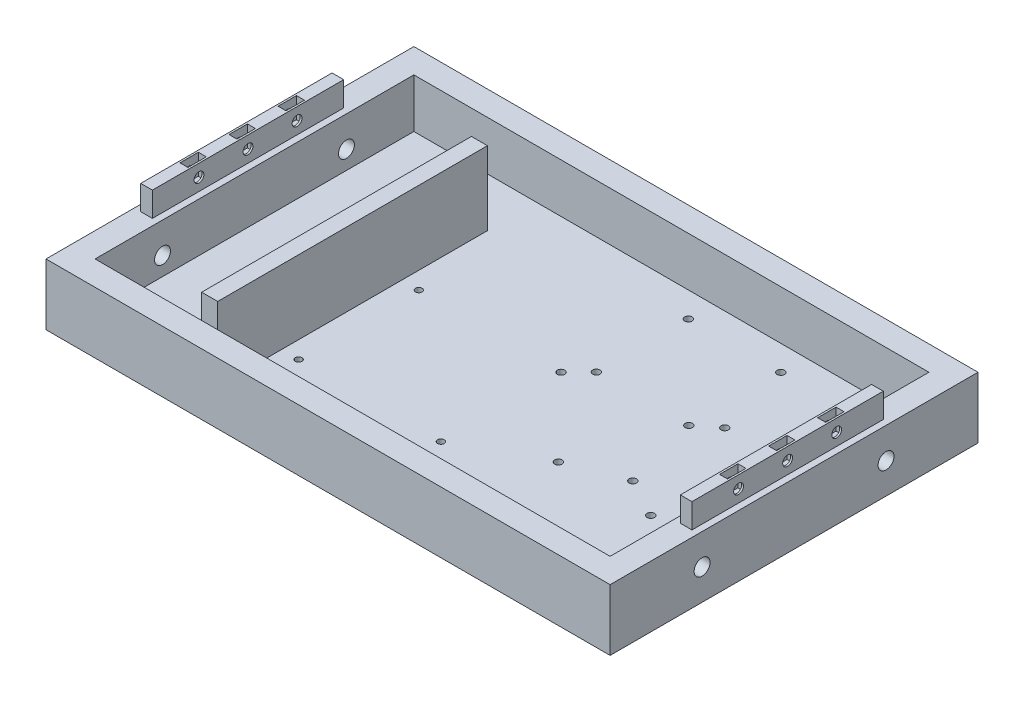
from build123d import *

# Parameters (mm, degrees)
SKETCH1_W           = 230
SKETCH1_H           = 25
BOSS_EXTRUDE1_DEPTH = 150
SKETCH2_W           = 210
SKETCH2_H           = 130
CUT_EXTRUDE1_DEPTH  = 20
SKETCH4_W           = 6.527967864
SKETCH4_H           = 110
BOSS_EXTRUDE3_DEPTH = 30
CUT_EXTRUDE2_REACH  = 7
SKETCH5_R           = 1.35
SKETCH5_R_2         = 1.5
SKETCH6_R           = 1.5
CUT_EXTRUDE3_DEPTH  = 6
CUT_EXTRUDE4_REACH  = 232
SKETCH7_R           = 3.25
CUT_EXTRUDE5_REACH  = 12
SKETCH8_R           = 3.25
SKETCH9_W           = 4.75
SKETCH9_H           = 80
BOSS_EXTRUDE4_DEPTH = 10
SKETCH10_R          = 2
CUT_EXTRUDE6_DEPTH  = 10
SKETCH11_R          = 2
CUT_EXTRUDE7_DEPTH  = 10
SKETCH12_W          = 3.25
SKETCH12_H          = 7.5
CUT_EXTRUDE8_DEPTH  = 8.5
SKETCH13_W          = 4.75
SKETCH13_H          = 1
CUT_EXTRUDE9_DEPTH  = 10


with BuildPart() as part:
    # Sketch1 → Boss-Extrude1 (new body)
    with BuildSketch(Plane.XY):
        with Locations((115, 12.5)):
            Rectangle(SKETCH1_W, SKETCH1_H)
    extrude(amount=BOSS_EXTRUDE1_DEPTH)

    # Sketch2 → Cut-Extrude1 (cut)
    with BuildSketch(Plane(origin=(0, 25, 0), x_dir=(1, 0, 0), z_dir=(0, 1, 0))):
        with Locations((115, -75)):
            Rectangle(SKETCH2_W, SKETCH2_H)
    extrude(amount=-CUT_EXTRUDE1_DEPTH, mode=Mode.SUBTRACT)

    # Sketch4 → Boss-Extrude3 (add)
    with BuildSketch(Plane(origin=(0, 5, 0), x_dir=(1, 0, 0), z_dir=(0, 1, 0))):
        with Locations((56.736016068, -85)):
            Rectangle(SKETCH4_W, SKETCH4_H)
    extrude(amount=BOSS_EXTRUDE3_DEPTH)

    # Sketch5 → Cut-Extrude2 (cut, up to next)
    with BuildSketch(Plane(origin=(0, 5, 0), x_dir=(1, 0, 0), z_dir=(0, 1, 0)), mode=Mode.PRIVATE) as cut_extrude2_sk1:
        with Locations((67, -65)):
            Circle(SKETCH5_R)
    cut_extrude2_tool1 = extrude(cut_extrude2_sk1.sketch, amount=-CUT_EXTRUDE2_REACH, mode=Mode.PRIVATE) & part.part
    add(cut_extrude2_tool1.solids().sort_by_distance((67, 5, 65))[0], mode=Mode.SUBTRACT)
    # Sketch5 → Cut-Extrude2 (cut, up to next)
    with BuildSketch(Plane(origin=(0, 5, 0), x_dir=(1, 0, 0), z_dir=(0, 1, 0)), mode=Mode.PRIVATE) as cut_extrude2_sk2:
        with Locations((67, -114)):
            Circle(SKETCH5_R)
    cut_extrude2_tool2 = extrude(cut_extrude2_sk2.sketch, amount=-CUT_EXTRUDE2_REACH, mode=Mode.PRIVATE) & part.part
    add(cut_extrude2_tool2.solids().sort_by_distance((67, 5, 114))[0], mode=Mode.SUBTRACT)
    # Sketch5 → Cut-Extrude2 (cut, up to next)
    with BuildSketch(Plane(origin=(0, 5, 0), x_dir=(1, 0, 0), z_dir=(0, 1, 0)), mode=Mode.PRIVATE) as cut_extrude2_sk3:
        with Locations((125, -65)):
            Circle(SKETCH5_R_2)
    cut_extrude2_tool3 = extrude(cut_extrude2_sk3.sketch, amount=-CUT_EXTRUDE2_REACH, mode=Mode.PRIVATE) & part.part
    add(cut_extrude2_tool3.solids().sort_by_distance((125, 5, 65))[0], mode=Mode.SUBTRACT)
    # Sketch5 → Cut-Extrude2 (cut, up to next)
    with BuildSketch(Plane(origin=(0, 5, 0), x_dir=(1, 0, 0), z_dir=(0, 1, 0)), mode=Mode.PRIVATE) as cut_extrude2_sk4:
        with Locations((125, -114)):
            Circle(SKETCH5_R)
    cut_extrude2_tool4 = extrude(cut_extrude2_sk4.sketch, amount=-CUT_EXTRUDE2_REACH, mode=Mode.PRIVATE) & part.part
    add(cut_extrude2_tool4.solids().sort_by_distance((125, 5, 114))[0], mode=Mode.SUBTRACT)

    # Sketch6 → Cut-Extrude3 (cut, through all)
    with BuildSketch(Plane(origin=(0, 5, 0), x_dir=(1, 0, 0), z_dir=(0, 1, 0))):
        with Locations((132.15, -20.25)):
            Circle(SKETCH6_R)
        with Locations((169.85, -20.25)):
            Circle(SKETCH6_R)
        with Locations((169.85, -57.75)):
            Circle(SKETCH6_R)
        with Locations((132.15, -57.75)):
            Circle(SKETCH6_R)
        with Locations((178, -51.25)):
            Circle(SKETCH6_R)
        with Locations((215.7, -51.25)):
            Circle(SKETCH6_R)
        with Locations((215.7, -88.75)):
            Circle(SKETCH6_R)
        with Locations((178, -88.75)):
            Circle(SKETCH6_R)
        with Locations((156.15, -97.25)):
            Circle(SKETCH6_R)
        with Locations((193.85, -97.25)):
            Circle(SKETCH6_R)
        with Locations((193.85, -134.75)):
            Circle(SKETCH6_R)
        with Locations((156.15, -134.75)):
            Circle(SKETCH6_R)
    extrude(amount=-CUT_EXTRUDE3_DEPTH, mode=Mode.SUBTRACT)

    # Sketch7 → Cut-Extrude4 (cut, up to next)
    with BuildSketch(Plane.ZY, mode=Mode.PRIVATE) as cut_extrude4_sk1:
        with Locations((37.5, 12.5)):
            Circle(SKETCH7_R)
    cut_extrude4_tool1 = extrude(cut_extrude4_sk1.sketch, amount=-CUT_EXTRUDE4_REACH, mode=Mode.PRIVATE) & part.part
    add(cut_extrude4_tool1.solids().sort_by_distance((0, 12.5, 37.5))[0], mode=Mode.SUBTRACT)
    # Sketch7 → Cut-Extrude4 (cut, up to next)
    with BuildSketch(Plane.ZY, mode=Mode.PRIVATE) as cut_extrude4_sk2:
        with Locations((112.5, 12.5)):
            Circle(SKETCH7_R)
    cut_extrude4_tool2 = extrude(cut_extrude4_sk2.sketch, amount=-CUT_EXTRUDE4_REACH, mode=Mode.PRIVATE) & part.part
    add(cut_extrude4_tool2.solids().sort_by_distance((0, 12.5, 112.5))[0], mode=Mode.SUBTRACT)

    # Sketch8 → Cut-Extrude5 (cut, up to next)
    with BuildSketch(Plane.ZY.offset(-220), mode=Mode.PRIVATE) as cut_extrude5_sk1:
        with Locations((112.5, 12.5)):
            Circle(SKETCH8_R)
    cut_extrude5_tool1 = extrude(cut_extrude5_sk1.sketch, amount=-CUT_EXTRUDE5_REACH, mode=Mode.PRIVATE) & part.part
    add(cut_extrude5_tool1.solids().sort_by_distance((220, 12.5, 112.5))[0], mode=Mode.SUBTRACT)
    # Sketch8 → Cut-Extrude5 (cut, up to next)
    with BuildSketch(Plane.ZY.offset(-220), mode=Mode.PRIVATE) as cut_extrude5_sk2:
        with Locations((37.5, 12.5)):
            Circle(SKETCH8_R)
    cut_extrude5_tool2 = extrude(cut_extrude5_sk2.sketch, amount=-CUT_EXTRUDE5_REACH, mode=Mode.PRIVATE) & part.part
    add(cut_extrude5_tool2.solids().sort_by_distance((220, 12.5, 37.5))[0], mode=Mode.SUBTRACT)

    # Sketch9 → Boss-Extrude4 (add)
    with BuildSketch(Plane(origin=(0, 25, 0), x_dir=(1, 0, 0), z_dir=(0, 1, 0))):
        with Locations((5, -75)):
            Rectangle(SKETCH9_W, SKETCH9_H)
        with Locations((225, -75)):
            Rectangle(SKETCH9_W, SKETCH9_H)
    extrude(amount=BOSS_EXTRUDE4_DEPTH)

    # Sketch10 → Cut-Extrude6 (cut)
    with BuildSketch(Plane.ZY.offset(-2.625)):
        with Locations((55, 30)):
            Circle(SKETCH10_R)
        with Locations((75, 30)):
            Circle(SKETCH10_R)
        with Locations((95, 30)):
            Circle(SKETCH10_R)
    extrude(amount=-CUT_EXTRUDE6_DEPTH, mode=Mode.SUBTRACT)

    # Sketch11 → Cut-Extrude7 (cut)
    with BuildSketch(Plane.ZY.offset(-222.625)):
        with Locations((95, 30)):
            Circle(SKETCH11_R)
        with Locations((75, 30)):
            Circle(SKETCH11_R)
        with Locations((55, 30)):
            Circle(SKETCH11_R)
    extrude(amount=-CUT_EXTRUDE7_DEPTH, mode=Mode.SUBTRACT)

    # Sketch12 → Cut-Extrude8 (cut)
    with BuildSketch(Plane(origin=(0, 35, 0), x_dir=(1, 0, 0), z_dir=(0, 1, 0))):
        with Locations((5, -75)):
            Rectangle(SKETCH12_W, SKETCH12_H)
        with Locations((5, -95)):
            Rectangle(SKETCH12_W, SKETCH12_H)
        with Locations((5, -55)):
            Rectangle(SKETCH12_W, SKETCH12_H)
        with Locations((225, -95)):
            Rectangle(SKETCH12_W, SKETCH12_H)
        with Locations((225, -75)):
            Rectangle(SKETCH12_W, SKETCH12_H)
        with Locations((225, -55)):
            Rectangle(SKETCH12_W, SKETCH12_H)
    extrude(amount=-CUT_EXTRUDE8_DEPTH, mode=Mode.SUBTRACT)

    # Sketch13 → Cut-Extrude9 (cut)
    with BuildSketch(Plane(origin=(0, 35, 0), x_dir=(1, 0, 0), z_dir=(0, 1, 0))):
        with Locations((225, -35.5)):
            Rectangle(SKETCH13_W, SKETCH13_H)
        with Locations((225, -114.5)):
            Rectangle(SKETCH13_W, SKETCH13_H)
        with Locations((5, -35.5)):
            Rectangle(SKETCH13_W, SKETCH13_H)
        with Locations((5, -114.5)):
            Rectangle(SKETCH13_W, SKETCH13_H)
    extrude(amount=-CUT_EXTRUDE9_DEPTH, mode=Mode.SUBTRACT)


solid = part.part
